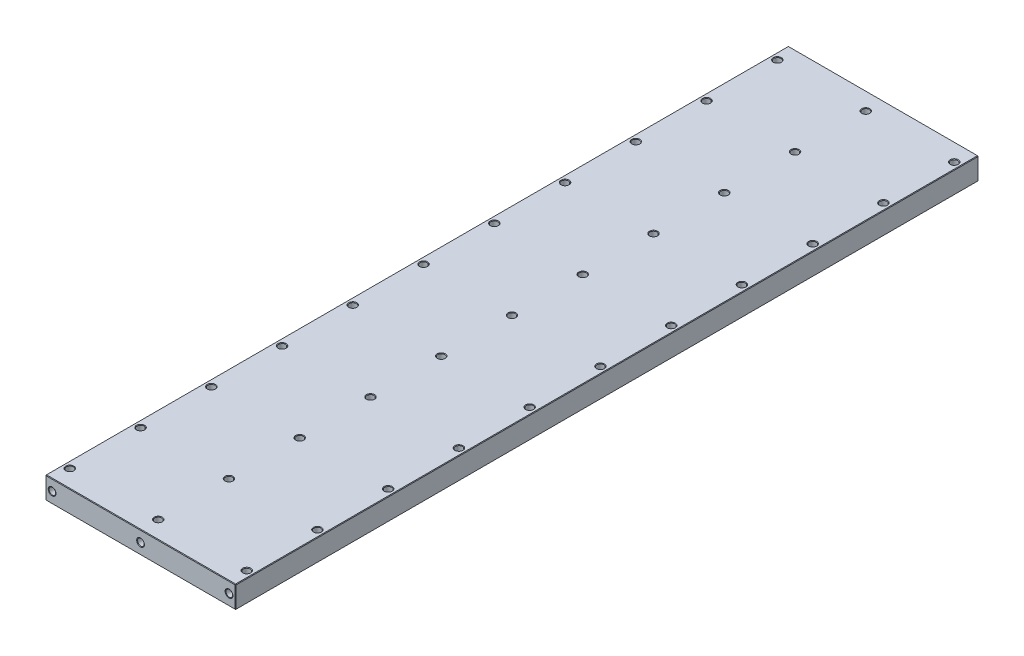
from build123d import *

# Parameters (mm, degrees)
SKETCH1_W                                     = 273.05
SKETCH1_H                                     = 31.75
BASE_EXTRUDE_DEPTH                            = 533.4
CBORE_FOR_3_8_SOCKET_HEAD_CAP_SCREW2_AT_COUNT = 2
CBORE_FOR_3_8_SOCKET_HEAD_CAP_SCREW2_AT_PITCH = 127
CBORE_FOR_3_8_SOCKET_HEAD_CAP_SCREW2_2_COUNT  = 2
CBORE_FOR_3_8_SOCKET_HEAD_CAP_SCREW2_2_PITCH  = 127
LPATTERN3_COUNT                               = 6
LPATTERN3_PITCH                               = 101.6
LPATTERN3_COL_COUNT                           = 6
LPATTERN3_COL_PITCH                           = 101.6
F_3_8_16_TAPPED_HOLE2_AT_2_COUNT              = 2
F_3_8_16_TAPPED_HOLE2_AT_2_PITCH              = 127
F_3_8_16_TAPPED_HOLE2_AT_3_COUNT              = 2
F_3_8_16_TAPPED_HOLE2_AT_3_PITCH              = 127
CHAMFER1_SIZE                                 = 0.762


with BuildPart() as part:
    # Sketch1 → Base-Extrude (new, symmetric)
    with BuildSketch(Plane.XY):
        Rectangle(SKETCH1_W, SKETCH1_H)
    extrude(amount=BASE_EXTRUDE_DEPTH, both=True)

    # Sketch6 → CBORE for 3_8 Socket Head Cap Screw2 (revolve, cut)
    with BuildSketch(Plane(origin=(0, -15.875, 0), x_dir=(0, 0, -1), z_dir=(1, 0, 0))):
        Polygon((0, 0), (0, 31.75), (5.842, 31.75), (5.15874, 30.963999282), (5.15874, 10.668), (8.7376, 10.668), (8.7376, 0), align=None)
    cbore_for_3_8_socket_head_cap_screw2 = revolve(axis=Axis((0, -22.225, 0), (0, 1, 0)), mode=Mode.SUBTRACT)

    # CBORE for 3_8 Socket Head Cap Screw2 at: CBORE for 3_8 Socket Head Cap Screw2 ×2
    with Locations(*[(i * CBORE_FOR_3_8_SOCKET_HEAD_CAP_SCREW2_AT_PITCH, 0, 0) for i in range(1, CBORE_FOR_3_8_SOCKET_HEAD_CAP_SCREW2_AT_COUNT)]):
        add(cbore_for_3_8_socket_head_cap_screw2, mode=Mode.SUBTRACT)

    # CBORE for 3_8 Socket Head Cap Screw2 2: CBORE for 3_8 Socket Head Cap Screw2 ×2
    with Locations(*[(-i * CBORE_FOR_3_8_SOCKET_HEAD_CAP_SCREW2_2_PITCH, 0, 0) for i in range(1, CBORE_FOR_3_8_SOCKET_HEAD_CAP_SCREW2_2_COUNT)]):
        add(cbore_for_3_8_socket_head_cap_screw2, mode=Mode.SUBTRACT)

    # LPattern3: CBORE for 3_8 Socket Head Cap Screw2 ×6
    with Locations(*[(0, 0, -i * LPATTERN3_PITCH) for i in range(1, LPATTERN3_COUNT)]):
        add(cbore_for_3_8_socket_head_cap_screw2, mode=Mode.SUBTRACT)

    # LPattern3 copy 1 sketch → LPattern3 copy 1 (revolve, cut)
    with BuildSketch(Plane(origin=(127, -15.875, -101.6), x_dir=(0, 0, -1), z_dir=(1, 0, 0))):
        Polygon((0, 0), (0, 31.75), (5.842, 31.75), (5.15874, 30.963999282), (5.15874, 10.668), (8.7376, 10.668), (8.7376, 0), align=None)
    revolve(axis=Axis((127, -22.225, -101.6), (0, 1, 0)), mode=Mode.SUBTRACT)

    # LPattern3 copy 2 sketch → LPattern3 copy 2 (revolve, cut)
    with BuildSketch(Plane(origin=(127, -15.875, -203.2), x_dir=(0, 0, -1), z_dir=(1, 0, 0))):
        Polygon((0, 0), (0, 31.75), (5.842, 31.75), (5.15874, 30.963999282), (5.15874, 10.668), (8.7376, 10.668), (8.7376, 0), align=None)
    revolve(axis=Axis((127, -22.225, -203.2), (0, 1, 0)), mode=Mode.SUBTRACT)

    # LPattern3 copy 3 sketch → LPattern3 copy 3 (revolve, cut)
    with BuildSketch(Plane(origin=(127, -15.875, -304.8), x_dir=(0, 0, -1), z_dir=(1, 0, 0))):
        Polygon((0, 0), (0, 31.75), (5.842, 31.75), (5.15874, 30.963999282), (5.15874, 10.668), (8.7376, 10.668), (8.7376, 0), align=None)
    revolve(axis=Axis((127, -22.225, -304.8), (0, 1, 0)), mode=Mode.SUBTRACT)

    # LPattern3 copy 4 sketch → LPattern3 copy 4 (revolve, cut)
    with BuildSketch(Plane(origin=(127, -15.875, -406.4), x_dir=(0, 0, -1), z_dir=(1, 0, 0))):
        Polygon((0, 0), (0, 31.75), (5.842, 31.75), (5.15874, 30.963999282), (5.15874, 10.668), (8.7376, 10.668), (8.7376, 0), align=None)
    revolve(axis=Axis((127, -22.225, -406.4), (0, 1, 0)), mode=Mode.SUBTRACT)

    # LPattern3 copy 5 sketch → LPattern3 copy 5 (revolve, cut)
    with BuildSketch(Plane(origin=(127, -15.875, -508), x_dir=(0, 0, -1), z_dir=(1, 0, 0))):
        Polygon((0, 0), (0, 31.75), (5.842, 31.75), (5.15874, 30.963999282), (5.15874, 10.668), (8.7376, 10.668), (8.7376, 0), align=None)
    revolve(axis=Axis((127, -22.225, -508), (0, 1, 0)), mode=Mode.SUBTRACT)

    # LPattern3 copy 6 sketch → LPattern3 copy 6 (revolve, cut)
    with BuildSketch(Plane(origin=(-127, -15.875, -101.6), x_dir=(0, 0, -1), z_dir=(1, 0, 0))):
        Polygon((0, 0), (0, 31.75), (5.842, 31.75), (5.15874, 30.963999282), (5.15874, 10.668), (8.7376, 10.668), (8.7376, 0), align=None)
    revolve(axis=Axis((-127, -22.225, -101.6), (0, 1, 0)), mode=Mode.SUBTRACT)

    # LPattern3 copy 7 sketch → LPattern3 copy 7 (revolve, cut)
    with BuildSketch(Plane(origin=(-127, -15.875, -203.2), x_dir=(0, 0, -1), z_dir=(1, 0, 0))):
        Polygon((0, 0), (0, 31.75), (5.842, 31.75), (5.15874, 30.963999282), (5.15874, 10.668), (8.7376, 10.668), (8.7376, 0), align=None)
    revolve(axis=Axis((-127, -22.225, -203.2), (0, 1, 0)), mode=Mode.SUBTRACT)

    # LPattern3 copy 8 sketch → LPattern3 copy 8 (revolve, cut)
    with BuildSketch(Plane(origin=(-127, -15.875, -304.8), x_dir=(0, 0, -1), z_dir=(1, 0, 0))):
        Polygon((0, 0), (0, 31.75), (5.842, 31.75), (5.15874, 30.963999282), (5.15874, 10.668), (8.7376, 10.668), (8.7376, 0), align=None)
    revolve(axis=Axis((-127, -22.225, -304.8), (0, 1, 0)), mode=Mode.SUBTRACT)

    # LPattern3 copy 9 sketch → LPattern3 copy 9 (revolve, cut)
    with BuildSketch(Plane(origin=(-127, -15.875, -406.4), x_dir=(0, 0, -1), z_dir=(1, 0, 0))):
        Polygon((0, 0), (0, 31.75), (5.842, 31.75), (5.15874, 30.963999282), (5.15874, 10.668), (8.7376, 10.668), (8.7376, 0), align=None)
    revolve(axis=Axis((-127, -22.225, -406.4), (0, 1, 0)), mode=Mode.SUBTRACT)

    # LPattern3 copy 10 sketch → LPattern3 copy 10 (revolve, cut)
    with BuildSketch(Plane(origin=(-127, -15.875, -508), x_dir=(0, 0, -1), z_dir=(1, 0, 0))):
        Polygon((0, 0), (0, 31.75), (5.842, 31.75), (5.15874, 30.963999282), (5.15874, 10.668), (8.7376, 10.668), (8.7376, 0), align=None)
    revolve(axis=Axis((-127, -22.225, -508), (0, 1, 0)), mode=Mode.SUBTRACT)

    # LPattern3 col: CBORE for 3_8 Socket Head Cap Screw2 ×6
    with Locations(*[(0, 0, i * LPATTERN3_COL_PITCH) for i in range(1, LPATTERN3_COL_COUNT)]):
        add(cbore_for_3_8_socket_head_cap_screw2, mode=Mode.SUBTRACT)

    # LPattern3 col copy 1 sketch → LPattern3 col copy 1 (revolve, cut)
    with BuildSketch(Plane(origin=(127, -15.875, 101.6), x_dir=(0, 0, -1), z_dir=(1, 0, 0))):
        Polygon((0, 0), (0, 31.75), (5.842, 31.75), (5.15874, 30.963999282), (5.15874, 10.668), (8.7376, 10.668), (8.7376, 0), align=None)
    revolve(axis=Axis((127, -22.225, 101.6), (0, 1, 0)), mode=Mode.SUBTRACT)

    # LPattern3 col copy 2 sketch → LPattern3 col copy 2 (revolve, cut)
    with BuildSketch(Plane(origin=(127, -15.875, 203.2), x_dir=(0, 0, -1), z_dir=(1, 0, 0))):
        Polygon((0, 0), (0, 31.75), (5.842, 31.75), (5.15874, 30.963999282), (5.15874, 10.668), (8.7376, 10.668), (8.7376, 0), align=None)
    revolve(axis=Axis((127, -22.225, 203.2), (0, 1, 0)), mode=Mode.SUBTRACT)

    # LPattern3 col copy 3 sketch → LPattern3 col copy 3 (revolve, cut)
    with BuildSketch(Plane(origin=(127, -15.875, 304.8), x_dir=(0, 0, -1), z_dir=(1, 0, 0))):
        Polygon((0, 0), (0, 31.75), (5.842, 31.75), (5.15874, 30.963999282), (5.15874, 10.668), (8.7376, 10.668), (8.7376, 0), align=None)
    revolve(axis=Axis((127, -22.225, 304.8), (0, 1, 0)), mode=Mode.SUBTRACT)

    # LPattern3 col copy 4 sketch → LPattern3 col copy 4 (revolve, cut)
    with BuildSketch(Plane(origin=(127, -15.875, 406.4), x_dir=(0, 0, -1), z_dir=(1, 0, 0))):
        Polygon((0, 0), (0, 31.75), (5.842, 31.75), (5.15874, 30.963999282), (5.15874, 10.668), (8.7376, 10.668), (8.7376, 0), align=None)
    revolve(axis=Axis((127, -22.225, 406.4), (0, 1, 0)), mode=Mode.SUBTRACT)

    # LPattern3 col copy 5 sketch → LPattern3 col copy 5 (revolve, cut)
    with BuildSketch(Plane(origin=(127, -15.875, 508), x_dir=(0, 0, -1), z_dir=(1, 0, 0))):
        Polygon((0, 0), (0, 31.75), (5.842, 31.75), (5.15874, 30.963999282), (5.15874, 10.668), (8.7376, 10.668), (8.7376, 0), align=None)
    revolve(axis=Axis((127, -22.225, 508), (0, 1, 0)), mode=Mode.SUBTRACT)

    # LPattern3 col copy 6 sketch → LPattern3 col copy 6 (revolve, cut)
    with BuildSketch(Plane(origin=(-127, -15.875, 101.6), x_dir=(0, 0, -1), z_dir=(1, 0, 0))):
        Polygon((0, 0), (0, 31.75), (5.842, 31.75), (5.15874, 30.963999282), (5.15874, 10.668), (8.7376, 10.668), (8.7376, 0), align=None)
    revolve(axis=Axis((-127, -22.225, 101.6), (0, 1, 0)), mode=Mode.SUBTRACT)

    # LPattern3 col copy 7 sketch → LPattern3 col copy 7 (revolve, cut)
    with BuildSketch(Plane(origin=(-127, -15.875, 203.2), x_dir=(0, 0, -1), z_dir=(1, 0, 0))):
        Polygon((0, 0), (0, 31.75), (5.842, 31.75), (5.15874, 30.963999282), (5.15874, 10.668), (8.7376, 10.668), (8.7376, 0), align=None)
    revolve(axis=Axis((-127, -22.225, 203.2), (0, 1, 0)), mode=Mode.SUBTRACT)

    # LPattern3 col copy 8 sketch → LPattern3 col copy 8 (revolve, cut)
    with BuildSketch(Plane(origin=(-127, -15.875, 304.8), x_dir=(0, 0, -1), z_dir=(1, 0, 0))):
        Polygon((0, 0), (0, 31.75), (5.842, 31.75), (5.15874, 30.963999282), (5.15874, 10.668), (8.7376, 10.668), (8.7376, 0), align=None)
    revolve(axis=Axis((-127, -22.225, 304.8), (0, 1, 0)), mode=Mode.SUBTRACT)

    # LPattern3 col copy 9 sketch → LPattern3 col copy 9 (revolve, cut)
    with BuildSketch(Plane(origin=(-127, -15.875, 406.4), x_dir=(0, 0, -1), z_dir=(1, 0, 0))):
        Polygon((0, 0), (0, 31.75), (5.842, 31.75), (5.15874, 30.963999282), (5.15874, 10.668), (8.7376, 10.668), (8.7376, 0), align=None)
    revolve(axis=Axis((-127, -22.225, 406.4), (0, 1, 0)), mode=Mode.SUBTRACT)

    # LPattern3 col copy 10 sketch → LPattern3 col copy 10 (revolve, cut)
    with BuildSketch(Plane(origin=(-127, -15.875, 508), x_dir=(0, 0, -1), z_dir=(1, 0, 0))):
        Polygon((0, 0), (0, 31.75), (5.842, 31.75), (5.15874, 30.963999282), (5.15874, 10.668), (8.7376, 10.668), (8.7376, 0), align=None)
    revolve(axis=Axis((-127, -22.225, 508), (0, 1, 0)), mode=Mode.SUBTRACT)

    # Sketch8 → 3_8-16 Tapped Hole2 (revolve, cut)
    with BuildSketch(Plane(origin=(0, 0, 533.4), x_dir=(0, -1, 0), z_dir=(1, 0, 0))):
        Polygon((0, 0), (0, 26.209865582), (3.96875, 23.8252), (3.96875, 19.05), (4.7625, 19.05), (4.7625, 0.476602647), (5.588, 0), align=None)
    f_3_8_16_tapped_hole2 = revolve(axis=Axis((0, 0, 539.75), (0, 0, -1)), mode=Mode.SUBTRACT)

    # 3_8-16 Tapped Hole2 at 2: 3_8-16 Tapped Hole2 ×2
    with Locations(*[(i * F_3_8_16_TAPPED_HOLE2_AT_2_PITCH, 0, 0) for i in range(1, F_3_8_16_TAPPED_HOLE2_AT_2_COUNT)]):
        add(f_3_8_16_tapped_hole2, mode=Mode.SUBTRACT)

    # 3_8-16 Tapped Hole2 at 3: 3_8-16 Tapped Hole2 ×2
    with Locations(*[(-i * F_3_8_16_TAPPED_HOLE2_AT_3_PITCH, 0, 0) for i in range(1, F_3_8_16_TAPPED_HOLE2_AT_3_COUNT)]):
        add(f_3_8_16_tapped_hole2, mode=Mode.SUBTRACT)

    # Mirror1: 3_8-16 Tapped Hole2 across plane
    add(f_3_8_16_tapped_hole2.mirror(Plane.XY), mode=Mode.SUBTRACT)

    # Mirror1 copy 1 sketch → Mirror1 copy 1 (revolve, cut)
    with BuildSketch(Plane(origin=(127, 0, -533.4), x_dir=(0, -1, 0), z_dir=(1, 0, 0))):
        Polygon((0, 0), (0, -26.209865582), (3.96875, -23.8252), (3.96875, -19.05), (4.7625, -19.05), (4.7625, -0.476602647), (5.588, 0), align=None)
    revolve(axis=Axis((127, 0, -539.75), (0, 0, -1)), mode=Mode.SUBTRACT)

    # Mirror1 copy 2 sketch → Mirror1 copy 2 (revolve, cut)
    with BuildSketch(Plane(origin=(-127, 0, -533.4), x_dir=(0, -1, 0), z_dir=(1, 0, 0))):
        Polygon((0, 0), (0, -26.209865582), (3.96875, -23.8252), (3.96875, -19.05), (4.7625, -19.05), (4.7625, -0.476602647), (5.588, 0), align=None)
    revolve(axis=Axis((-127, 0, -539.75), (0, 0, -1)), mode=Mode.SUBTRACT)

    # Chamfer1
    chamfer1_edges = [part.edges().sort_by_distance(p)[0] for p in [
        (136.525, 0, 533.4),
        (0, 15.875, 533.4),
        (-136.525, 0, 533.4),
        (0, 15.875, -533.4),
        (136.525, 0, -533.4),
        (0, -15.875, -533.4),
        (-136.525, 0, -533.4),
        (0, -15.875, 533.4),
        (-136.525, 15.875, 0),
        (136.525, 15.875, 0),
        (136.525, -15.875, 0),
        (-136.525, -15.875, 0),
    ]]
    chamfer(chamfer1_edges, length=CHAMFER1_SIZE)


solid = part.part
